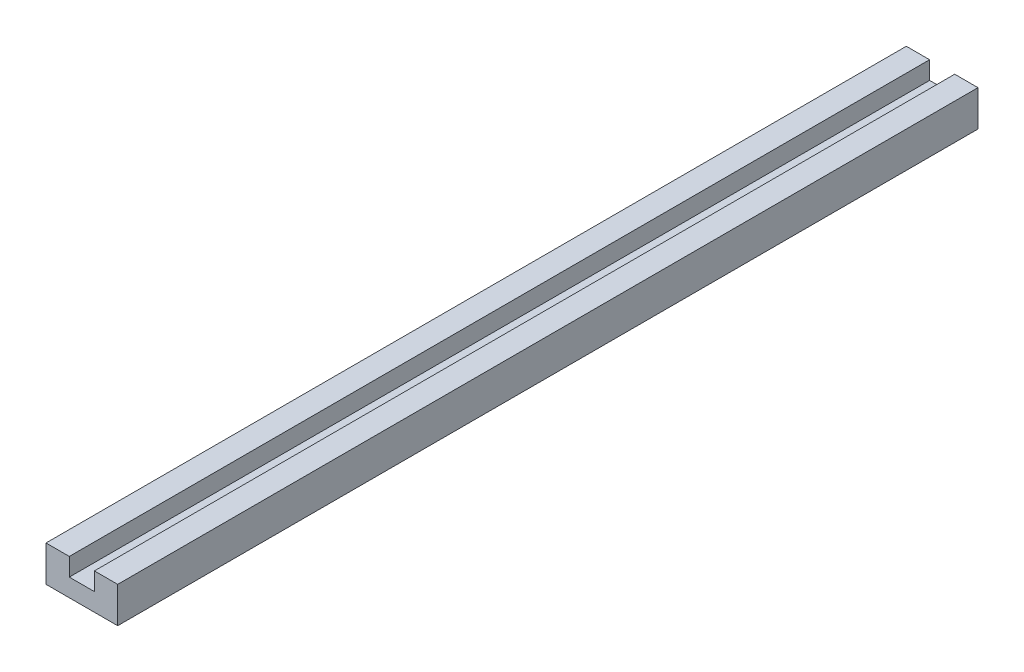
from build123d import *

# Parameters (mm, degrees)
SKETCH2_W           = 20
SKETCH2_H           = 10
BOSS_EXTRUDE1_DEPTH = 240
SKETCH4_W           = 7
SKETCH4_H           = 5
CUT_EXTRUDE1_DEPTH  = 241


with BuildPart() as part:
    # Sketch2 → Boss-Extrude1 (new body)
    with BuildSketch(Plane.XY):
        with Locations((10, 5)):
            Rectangle(SKETCH2_W, SKETCH2_H)
    extrude(amount=BOSS_EXTRUDE1_DEPTH)

    # Sketch4 → Cut-Extrude1 (cut, through all)
    with BuildSketch(Plane.XY.offset(240)):
        with Locations((10, 7.5)):
            Rectangle(SKETCH4_W, SKETCH4_H)
    extrude(amount=-CUT_EXTRUDE1_DEPTH, mode=Mode.SUBTRACT)


solid = part.part
